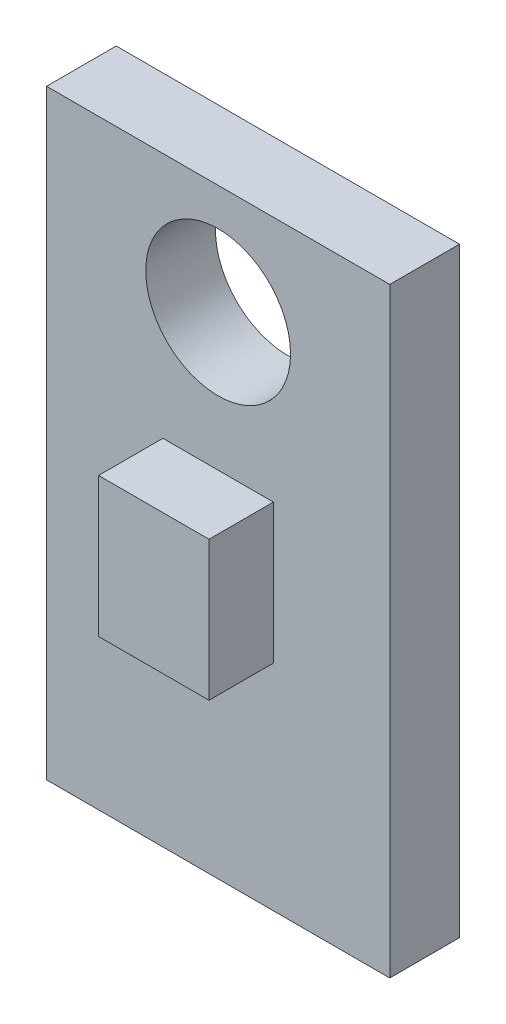
from build123d import *

# Parameters (mm, degrees)
SKETCH1_W           = 8.128
SKETCH1_H           = 14.224
BOSS_EXTRUDE1_DEPTH = 1.651
SKETCH2_W           = 2.6162
SKETCH2_H           = 3.302
BOSS_EXTRUDE2_DEPTH = 1.524
SKETCH3_R           = 1.7145
CUT_EXTRUDE1_DEPTH  = 2.651


with BuildPart() as part:
    # Sketch1 → Boss-Extrude1 (new body)
    with BuildSketch(Plane.XY):
        with Locations((4.064, 7.112)):
            Rectangle(SKETCH1_W, SKETCH1_H)
    extrude(amount=BOSS_EXTRUDE1_DEPTH)

    # Sketch2 → Boss-Extrude2 (add)
    with BuildSketch(Plane.XY.offset(1.651)):
        with Locations((4.064, 6.731)):
            Rectangle(SKETCH2_W, SKETCH2_H)
    extrude(amount=BOSS_EXTRUDE2_DEPTH)

    # Sketch3 → Cut-Extrude1 (cut, through all)
    with BuildSketch(Plane.XY.offset(1.651)):
        with Locations((4.064, 11.6205)):
            Circle(SKETCH3_R)
    extrude(amount=-CUT_EXTRUDE1_DEPTH, mode=Mode.SUBTRACT)


solid = part.part
